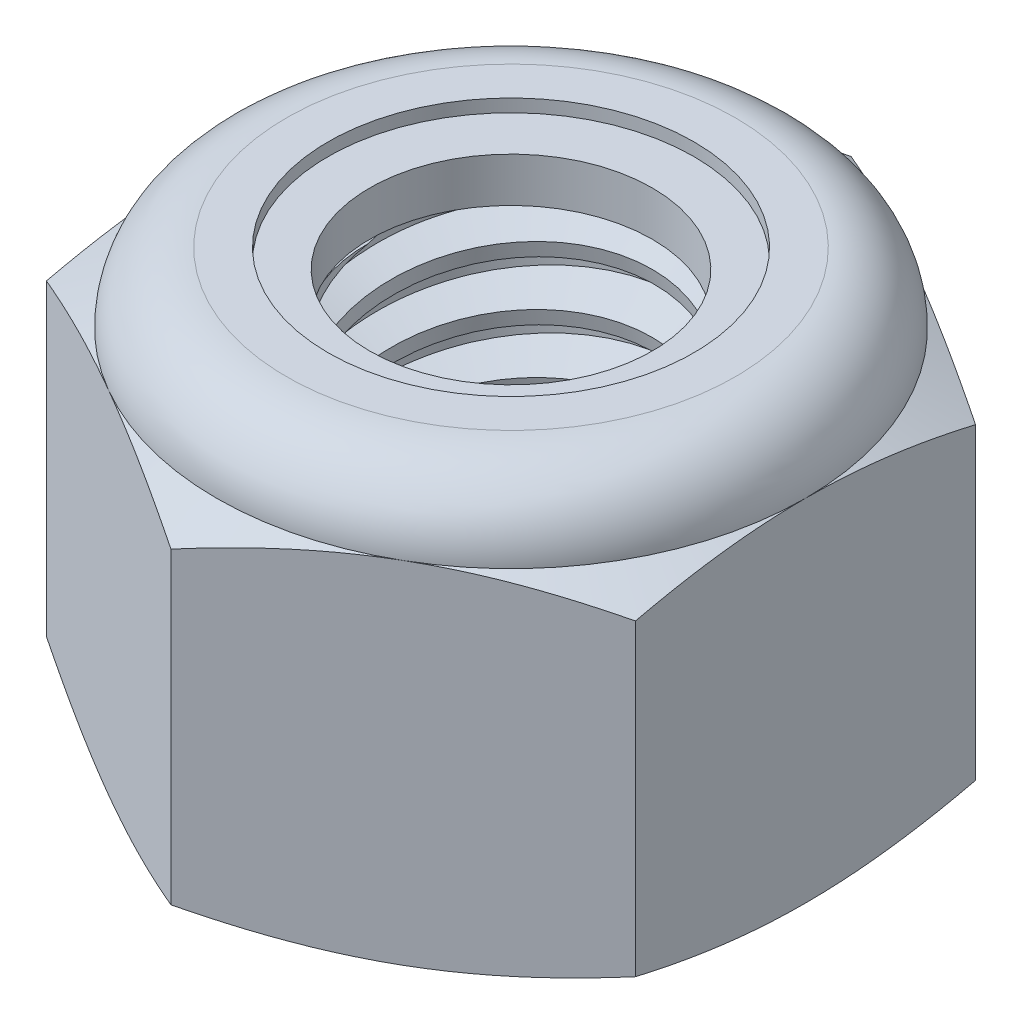
from build123d import *

# Parameters (mm, degrees)
EXTRUDE1_DEPTH      = 5
SKETCH2_W           = 2
SKETCH2_H           = 5
LPATTERN1_COUNT     = 7
LPATTERN1_PITCH     = 0.7
LPATTERN1_COL_COUNT = 2
LPATTERN1_COL_PITCH = 0.7


with BuildPart() as part:
    # Sketch1 → Extrude1 (new body)
    with BuildSketch(Plane(origin=(0, 0, 0), x_dir=(1, 0, 0), z_dir=(0, 1, 0))):
        Polygon((0, 4.041451884), (-3.5, 2.020725942), (-3.5, -2.020725942), (0, -4.041451884), (3.5, -2.020725942), (3.5, 2.020725942), align=None)
    extrude(amount=EXTRUDE1_DEPTH)

    # Sketch4 → Cut-Revolve2 (revolve, cut)
    with BuildSketch(Plane(origin=(0, 0, 0), x_dir=(0, 0, -1), z_dir=(1, 0, 0))):
        Polygon((0, 5), (2, 5), (1.679577111, 4.850584353), (1.679577111, 0.149415647), (2, 0), (0, 0), align=None)
    revolve(axis=Axis((0, 5, 0), (0, 1, 0)), mode=Mode.SUBTRACT)


with BuildPart() as body_2:
    # Sketch2 → Revolve1 (revolve)
    with BuildSketch(Plane(origin=(0, 0, 0), x_dir=(0, 0, -1), z_dir=(1, 0, 0))):
        with Locations((1, 2.5)):
            Rectangle(SKETCH2_W, SKETCH2_H)
    revolve(axis=Axis((0, -2, 0), (0, 1, 0)))

    # Sketch3 → Cut-Revolve1 (revolve, cut)
    with BuildSketch(Plane(origin=(0, 0, 0), x_dir=(0, 0, -1), z_dir=(1, 0, 0))):
        Polygon((2.015083279, 4.913809834), (2.120666232, 4.310478673), (1.709743669, 4.460641574), (1.679577111, 4.633021905), align=None)
    cut_revolve1 = revolve(axis=Axis((0, 5, 0.13120342), (0, -0.985030467, -0.172380332)), mode=Mode.SUBTRACT)

    # LPattern1: Cut-Revolve1 ×7
    with Locations(*[(0, -i * LPATTERN1_PITCH, 0) for i in range(1, LPATTERN1_COUNT)]):
        add(cut_revolve1, mode=Mode.SUBTRACT)

    # LPattern1 col: Cut-Revolve1 ×2
    with Locations(*[(0, i * LPATTERN1_COL_PITCH, 0) for i in range(1, LPATTERN1_COL_COUNT)]):
        add(cut_revolve1, mode=Mode.SUBTRACT)


with BuildPart() as part_1:
    add(part.part)

    # Combine1: cut body 2
    add(body_2.part, mode=Mode.SUBTRACT)

    # Sketch5 → Cut-Revolve3 (revolve, cut)
    with BuildSketch(Plane(origin=(0, 0, 0), x_dir=(0, 0, -1), z_dir=(1, 0, 0))):
        with BuildLine():
            Line((0, 0), (3.5, 0))
            Line((3.5, 0), (4.041451884, 0.25248316))
            Line((4.041451884, 0.25248316), (4.041451884, 3.914183506))
            Line((4.041451884, 3.914183506), (3.5, 4.166666667))
            ThreePointArc((3.5, 4.166666667), (3.255922318, 4.755922318), (2.666666667, 5))
            Line((2.666666667, 5), (2.666666667, 6.27))
            Line((2.666666667, 6.27), (5.311451884, 6.27))
            Line((5.311451884, 6.27), (5.311451884, -1.27))
            Line((5.311451884, -1.27), (0, -1.27))
            Line((0, -1.27), (0, 0))
        make_face()
    revolve(axis=Axis((0, 0, 0), (0, 1, 0)), mode=Mode.SUBTRACT)

    # Sketch6 → Cut-Revolve4 (revolve, cut)
    with BuildSketch(Plane(origin=(0, 0, 0), x_dir=(0, 0, -1), z_dir=(1, 0, 0))):
        with BuildLine():
            Line((0, 4.166666667), (3.3476, 4.166666667))
            ThreePointArc((3.3476, 4.166666667), (3.148159244, 4.648159244), (2.666666667, 4.8476))
            Line((2.666666667, 4.8476), (2.173121889, 4.8476))
            Line((2.173121889, 4.8476), (2.173121889, 6.27))
            Line((2.173121889, 6.27), (0, 6.27))
            Line((0, 6.27), (0, 4.166666667))
        make_face()
    revolve(axis=Axis((0, 6.27, 0), (0, 1, 0)), mode=Mode.SUBTRACT)


with BuildPart() as body_2_2:
    # Sketch7 → Revolve2 (revolve)
    with BuildSketch(Plane(origin=(0, 0, 0), x_dir=(0, 0, -1), z_dir=(1, 0, 0))):
        with BuildLine():
            Line((1.679577111, 4.242866667), (3.266579964, 4.242866667))
            ThreePointArc((3.266579964, 4.242866667), (3.066430175, 4.620419399), (2.666666667, 4.7714))
            Line((2.666666667, 4.7714), (1.679577111, 4.7714))
            Line((1.679577111, 4.7714), (1.679577111, 4.242866667))
        make_face()
    revolve(axis=Axis((0, 4.242866667, 0), (0, 1, 0)))


solid = Compound([part_1.part, body_2_2.part])
